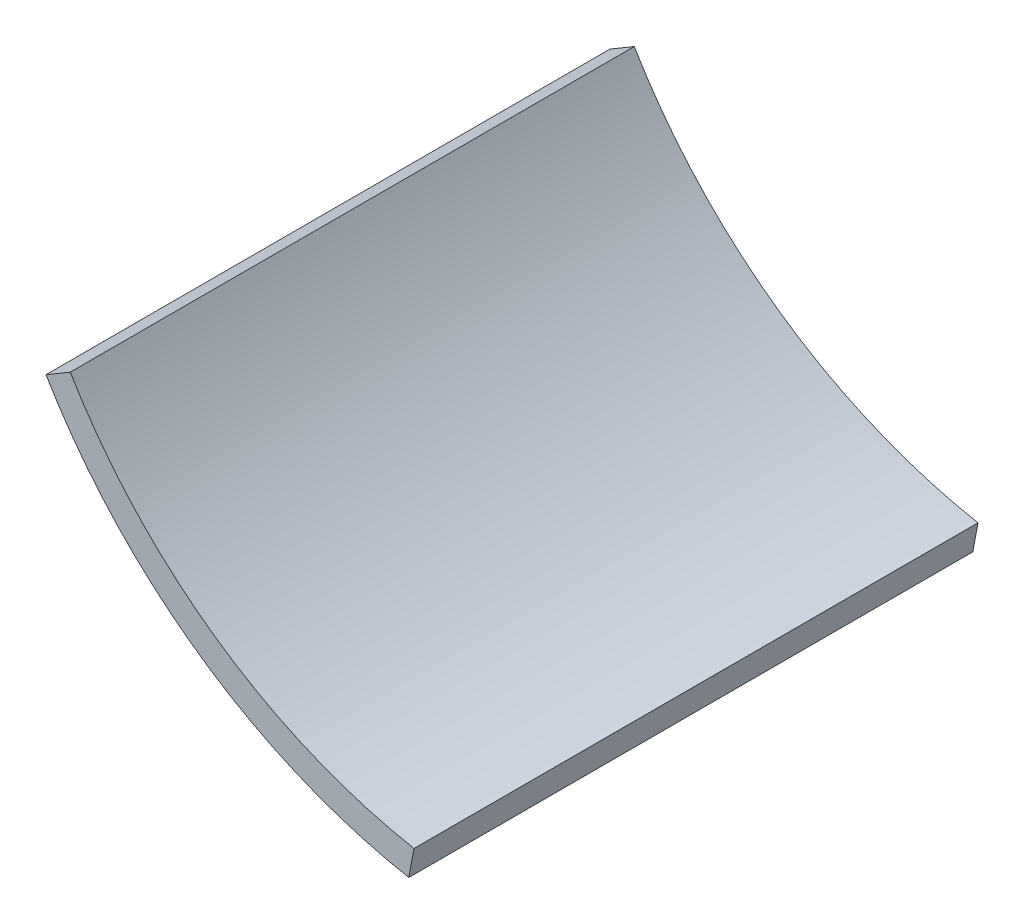
from build123d import *

# Parameters (mm, degrees)
SKETCH4_R           = 120.65
SKETCH4_R_2         = 114.3
BOSS_EXTRUDE3_DEPTH = 63.5
CUT_EXTRUDE1_DEPTH  = 127


with BuildPart() as part:
    # Sketch4 → Boss-Extrude3 (new body, symmetric)
    with BuildSketch(Plane.XY):
        Circle(SKETCH4_R)
        Circle(SKETCH4_R_2, mode=Mode.SUBTRACT)
    extrude(amount=BOSS_EXTRUDE3_DEPTH, both=True)

    # Sketch6 → Cut-Extrude1 (cut)
    with BuildSketch(Plane.XY.offset(63.5)):
        Polygon((-23.688348603, -126.768556463), (0, 0), (-123.610109983, -73.074966297), (-158.065889769, 116.718954026), (139.402342385, 136.243895905), (181.323541125, -82.26317424), (155.492233446, -108.890326726), align=None)
    extrude(amount=-CUT_EXTRUDE1_DEPTH, mode=Mode.SUBTRACT)


solid = part.part
